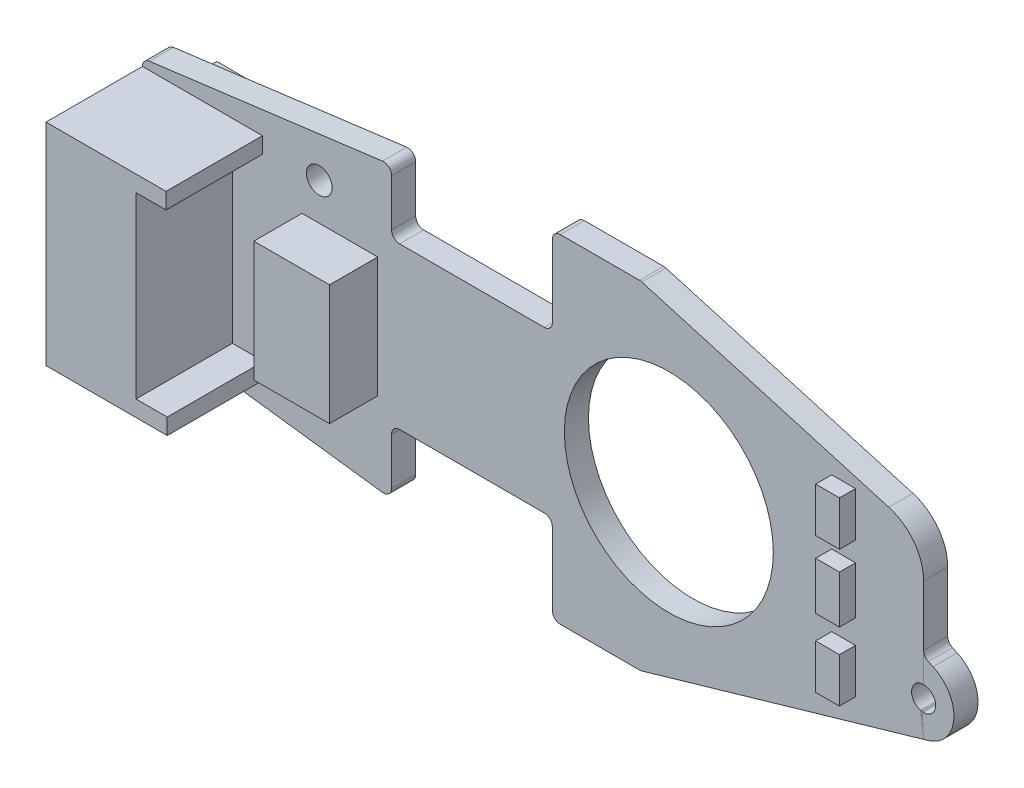
from build123d import *

# Parameters (mm, degrees)
ESQUISSE1_R      = 0.8
EXTRUSION1_DEPTH = 1.5
EXTRUSION2_DEPTH = 1.5
CONG_1_R         = 3
ESQUISSE3_R      = 0.75
EXTRUSION3_DEPTH = 2.5
EXTRUSION4_DEPTH = 6
ESQUISSE5_W      = 4.707583755
ESQUISSE5_H      = 7.480544049
EXTRUSION5_DEPTH = 3
ESQUISSE6_W      = 1.48321132
ESQUISSE6_H      = 2.772960294
ESQUISSE6_H_2    = 2.96642264
EXTRUSION6_DEPTH = 1
ESQUISSE7_W      = 2.643985397
ESQUISSE7_H      = 4.320659063
ESQUISSE7_H_2    = 4.514121409
ESQUISSE7_W_2    = 3.224372435
ESQUISSE7_H_3    = 4.707583755
ESQUISSE7_W_3    = 5.41694569
ESQUISSE7_H_4    = 5.223483344
EXTRUSION7_DEPTH = 1
ESQUISSE8_W      = 4.49521056
ESQUISSE8_H      = 11.598329537
EXTRUSION8_DEPTH = 4


with BuildPart() as part:
    # Esquisse1 → Extrusion1 (new body)
    with BuildSketch(Plane.XY):
        with BuildLine():
            Line((0, 0), (0, 6.56037098))
            ThreePointArc((0, 6.56037098), (0.124505104, 6.890527887), (0.436014331, 7.056259914))
            Line((0.436014331, 7.056259914), (14.936014331, 8.927227656))
            ThreePointArc((14.936014331, 8.927227656), (15.330156906, 8.806833619), (15.5, 8.431338722))
            Line((15.5, 8.431338722), (15.5, 5.5))
            ThreePointArc((15.5, 5.5), (15.646446609, 5.146446609), (16, 5))
            Line((16, 5), (25, 5))
            ThreePointArc((25, 5), (25.353553391, 5.146446609), (25.5, 5.5))
            Line((25.5, 5.5), (25.5, 10))
            ThreePointArc((25.5, 10), (25.646446609, 10.353553391), (26, 10.5))
            Line((26, 10.5), (30.929016868, 10.5))
            ThreePointArc((30.929016868, 10.5), (30.999295322, 10.495036301), (31.068178411, 10.480243756))
            Line((31.068178411, 10.480243756), (48.6, 5.4))
            Line((48.6, 5.4), (48.6, 0))
            Line((48.6, 0), (39.25, 0))
            ThreePointArc((39.25, 0), (32.75, 6.5), (26.25, 0))
            Line((26.25, 0), (0, 0))
        make_face()
        with Locations((11, 5.92)):
            Circle(ESQUISSE1_R, mode=Mode.SUBTRACT)
    extrude(amount=EXTRUSION1_DEPTH)

    # Symétrie1: part across plane


with BuildPart() as part_1:
    add(part.part)
    add(part.part.mirror(Plane.ZX))

    # Congé1
    cong_1_edges = [part_1.edges().sort_by_distance(p)[0] for p in [
        (48.6, 5.4, 0.75),
    ]]
    fillet(cong_1_edges, radius=CONG_1_R)


with BuildPart() as body_2:
    # Esquisse2 → Extrusion2 (new body)
    with BuildSketch(Plane.XY.offset(1.5)):
        with BuildLine():
            Line((48.6, -5.4), (48.899944248, -5.313084337))
            ThreePointArc((48.899944248, -5.313084337), (50.482348427, -3.352413296), (49.186123682, -1.191849637))
            Line((49.186123682, -1.191849637), (48.895797677, -1.061952221))
            ThreePointArc((48.895797677, -1.061952221), (48.680416181, -0.877488152), (48.6, -0.605551727))
            Line((48.6, -0.605551727), (48.6, -0.084955215))
            Line((48.6, -0.084955215), (47.845340425, -0.084955215))
            Line((47.845340425, -0.084955215), (48.6, -5.4))
        make_face()
    extrude(amount=-EXTRUSION2_DEPTH)


with BuildPart() as extrusion3_tool:
    # Esquisse3 → Extrusion3 (new body, through all)
    with BuildSketch(Plane.XY.offset(1.5)):
        with Locations((48.6, -3.2)):
            Circle(ESQUISSE3_R)
    extrude(amount=-EXTRUSION3_DEPTH)


with BuildPart() as part_2:
    add(part_1.part)

    # Extrusion3: cut by extrusion3_tool
    add(extrusion3_tool.part, mode=Mode.SUBTRACT)

    # Esquisse4 → Extrusion4 (add)
    with BuildSketch(Plane.XY.offset(1.5)):
        Polygon((0, 6.56037098), (7.467207895, 6.56037098), (7.467207895, 5.56037098), (5.598884499, 5.56037098), (5.598884499, -5.56037098), (7.541940831, -5.56037098), (7.541940831, -6.56037098), (0, -6.56037098), align=None)
    extrude(amount=EXTRUSION4_DEPTH)

    # Esquisse5 → Extrusion5 (add)
    with BuildSketch(Plane.XY.offset(1.5)):
        with Locations((12.284219752, -0.128974898)):
            Rectangle(ESQUISSE5_W, ESQUISSE5_H)
    extrude(amount=EXTRUSION5_DEPTH)

    # Esquisse6 → Extrusion6 (add)
    with BuildSketch(Plane.XY.offset(1.5)):
        with Locations((43.625119818, 4.610852582)):
            Rectangle(ESQUISSE6_W, ESQUISSE6_H)
        with Locations((43.625119818, 0.51589959)):
            Rectangle(ESQUISSE6_W, ESQUISSE6_H_2)
        with Locations((43.625119818, -3.837003197)):
            Rectangle(ESQUISSE6_W, ESQUISSE6_H)
    extrude(amount=EXTRUSION6_DEPTH)

    # Esquisse7 → Extrusion7 (add)
    with BuildSketch(Plane(origin=(0, 0, 0), x_dir=(-1, 0, 0), z_dir=(0, 0, -1))):
        with Locations((-3.449439281, 4.481877685)):
            Rectangle(ESQUISSE7_W, ESQUISSE7_H)
        with Locations((-3.449439281, -4.320659063)):
            Rectangle(ESQUISSE7_W, ESQUISSE7_H_2)
        with Locations((-17.217509577, 0.806093109)):
            Rectangle(ESQUISSE7_W_2, ESQUISSE7_H_3)
        with Locations((-44.044288234, 0.548143314)):
            Rectangle(ESQUISSE7_W_3, ESQUISSE7_H_4)
    extrude(amount=EXTRUSION7_DEPTH)

    # Esquisse8 → Extrusion8 (cut)
    with BuildSketch(Plane.ZY):
        with Locations((4.593129783, -0.034314585)):
            Rectangle(ESQUISSE8_W, ESQUISSE8_H)
    extrude(amount=-EXTRUSION8_DEPTH, mode=Mode.SUBTRACT)


with BuildPart() as body_2_1:
    add(body_2.part)

    # Extrusion3: cut by extrusion3_tool
    add(extrusion3_tool.part, mode=Mode.SUBTRACT)


solid = Compound([part_2.part, body_2_1.part])
